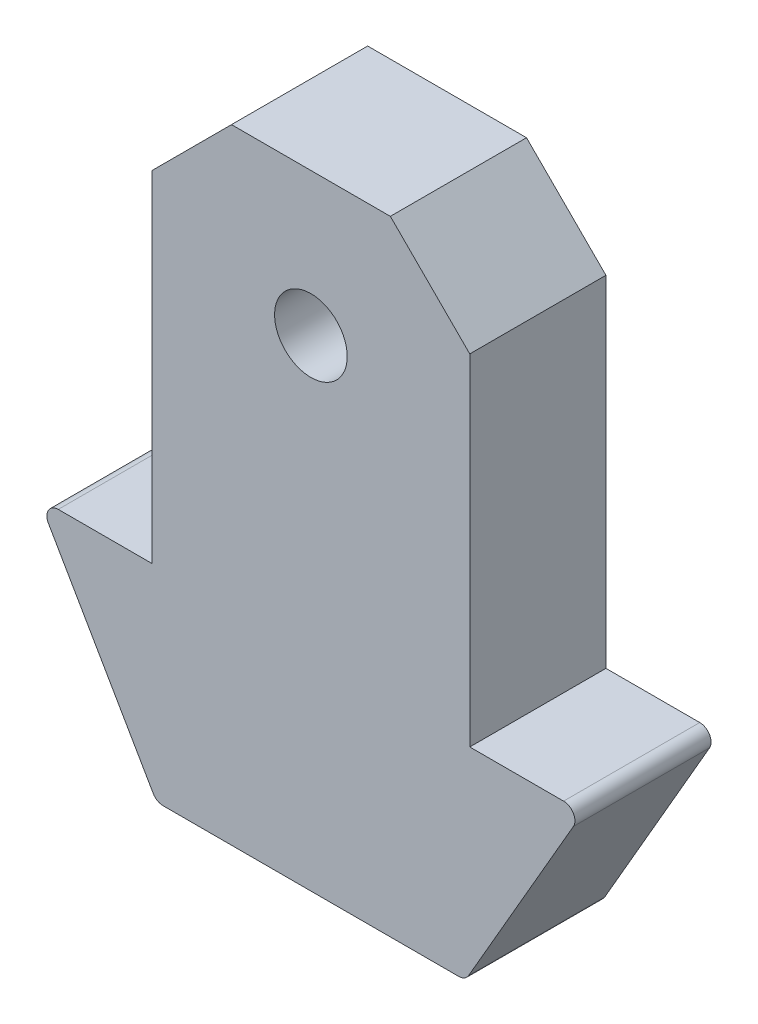
from build123d import *

# Parameters (mm, degrees)
BOSS_EXTRUDE1_DEPTH = 3
SKETCH2_R           = 1.6
CUT_EXTRUDE1_DEPTH  = 7
CHAMFER1_SIZE       = 3.5
FILLET1_R           = 0.5


with BuildPart() as part:
    # Sketch1 → Boss-Extrude1 (new body, symmetric)
    with BuildSketch(Plane.XY):
        Polygon((-7, 0), (7, 0), (7, -18.5), (12, -18.5), (6.803847577, -27.5), (-6.803847577, -27.5), (-12, -18.5), (-7, -18.5), align=None)
    extrude(amount=BOSS_EXTRUDE1_DEPTH, both=True)

    # Sketch2 → Cut-Extrude1 (cut, through all)
    with BuildSketch(Plane.XY.offset(3)):
        with Locations((0, -6.3)):
            Circle(SKETCH2_R)
    extrude(amount=-CUT_EXTRUDE1_DEPTH, mode=Mode.SUBTRACT)

    # Chamfer1
    chamfer1_edges = [part.edges().sort_by_distance(p)[0] for p in [
        (-7, 0, 0),
        (7, 0, 0),
    ]]
    chamfer(chamfer1_edges, length=CHAMFER1_SIZE)

    # Fillet1
    fillet1_edges = [part.edges().sort_by_distance(p)[0] for p in [
        (12, -18.5, 0),
        (6.803847577, -27.5, 0),
        (-6.803847577, -27.5, 0),
        (-12, -18.5, 0),
    ]]
    fillet(fillet1_edges, radius=FILLET1_R)


solid = part.part
